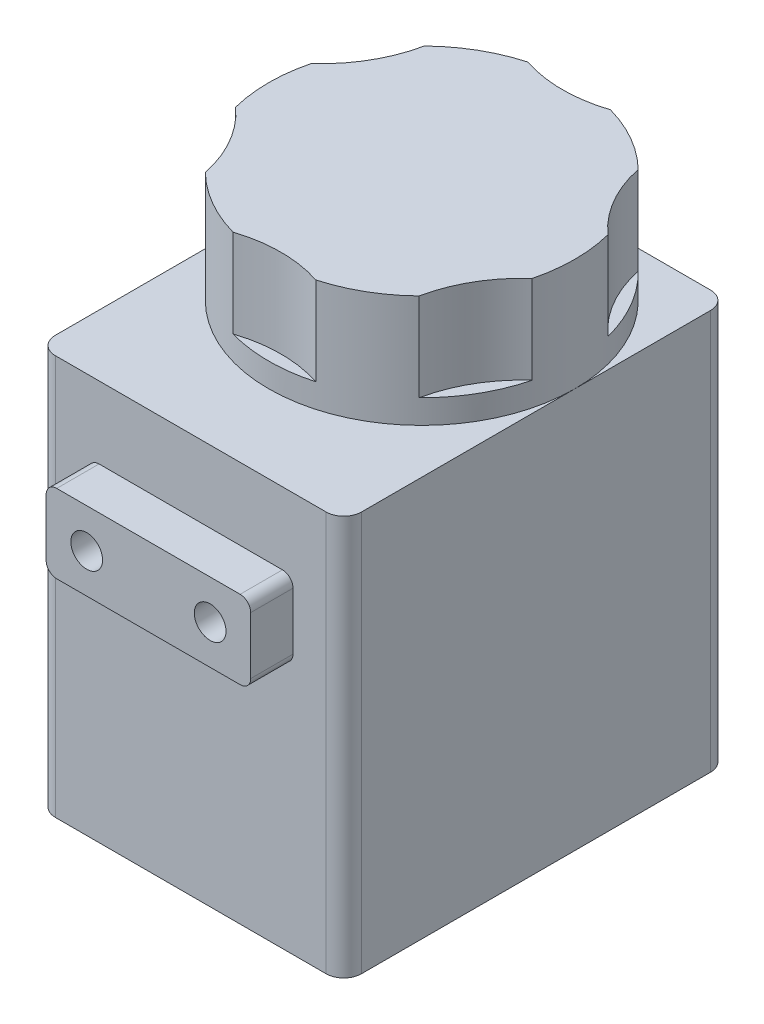
from build123d import *

# Parameters (mm, degrees)
SKETCH1_W           = 22.0472
SKETCH1_H           = 27.686
BOSS_EXTRUDE1_DEPTH = 28.8036
SKETCH2_W           = 14.732
SKETCH2_H           = 5.6388
BOSS_EXTRUDE2_DEPTH = 3.048
SKETCH3_R           = 11.0236
BOSS_EXTRUDE3_DEPTH = 8.0772
SKETCH4_R           = 9.525
CUT_EXTRUDE1_DEPTH  = 6.35
FILLET1_R           = 1.27
FILLET2_R           = 0.762
SKETCH5_R           = 1.143
CUT_EXTRUDE2_DEPTH  = 2.54


with BuildPart() as part:
    # Sketch1 → Boss-Extrude1 (new body)
    with BuildSketch(Plane(origin=(0, 0, 0), x_dir=(1, 0, 0), z_dir=(0, 1, 0))):
        with Locations((11.0236, 13.843)):
            Rectangle(SKETCH1_W, SKETCH1_H)
    extrude(amount=BOSS_EXTRUDE1_DEPTH)

    # Sketch2 → Boss-Extrude2 (add)
    with BuildSketch(Plane.XY):
        with Locations((11.0236, 20.8026)):
            Rectangle(SKETCH2_W, SKETCH2_H)
    extrude(amount=BOSS_EXTRUDE2_DEPTH)

    # Sketch3 → Boss-Extrude3 (add)
    with BuildSketch(Plane(origin=(0, 28.8036, 0), x_dir=(1, 0, 0), z_dir=(0, 1, 0))):
        with Locations((11.0236, 16.637)):
            Circle(SKETCH3_R)
    extrude(amount=BOSS_EXTRUDE3_DEPTH)

    # Sketch4 → Cut-Extrude1 (cut)
    with BuildSketch(Plane(origin=(0, 36.8808, 0), x_dir=(1, 0, 0), z_dir=(0, 1, 0))):
        with Locations((11.0236, 36.2966)):
            Circle(SKETCH4_R)
        with Locations((28.049313028, 26.4668)):
            Circle(SKETCH4_R)
        with Locations((28.049313028, 6.8072)):
            Circle(SKETCH4_R)
        with Locations((11.0236, -3.0226)):
            Circle(SKETCH4_R)
        with Locations((-6.002113028, 6.8072)):
            Circle(SKETCH4_R)
        with Locations((-6.002113028, 26.4668)):
            Circle(SKETCH4_R)
    extrude(amount=-CUT_EXTRUDE1_DEPTH, mode=Mode.SUBTRACT)

    # Fillet1
    fillet1_edges = [part.edges().sort_by_distance(p)[0] for p in [
        (0, 14.4018, -27.686),
        (22.0472, 14.4018, -27.686),
        (22.0472, 14.4018, 0),
        (0, 14.4018, 0),
    ]]
    fillet(fillet1_edges, radius=FILLET1_R)

    # Fillet2
    fillet2_edges = [part.edges().sort_by_distance(p)[0] for p in [
        (18.3896, 17.9832, 1.524),
        (18.3896, 23.622, 1.524),
        (3.6576, 23.622, 1.524),
        (3.6576, 17.9832, 1.524),
    ]]
    fillet(fillet2_edges, radius=FILLET2_R)

    # Sketch5 → Cut-Extrude2 (cut)
    with BuildSketch(Plane.XY.offset(3.048)):
        with Locations((6.5786, 20.8026)):
            Circle(SKETCH5_R)
        with Locations((15.4686, 20.8026)):
            Circle(SKETCH5_R)
    extrude(amount=-CUT_EXTRUDE2_DEPTH, mode=Mode.SUBTRACT)


solid = part.part
